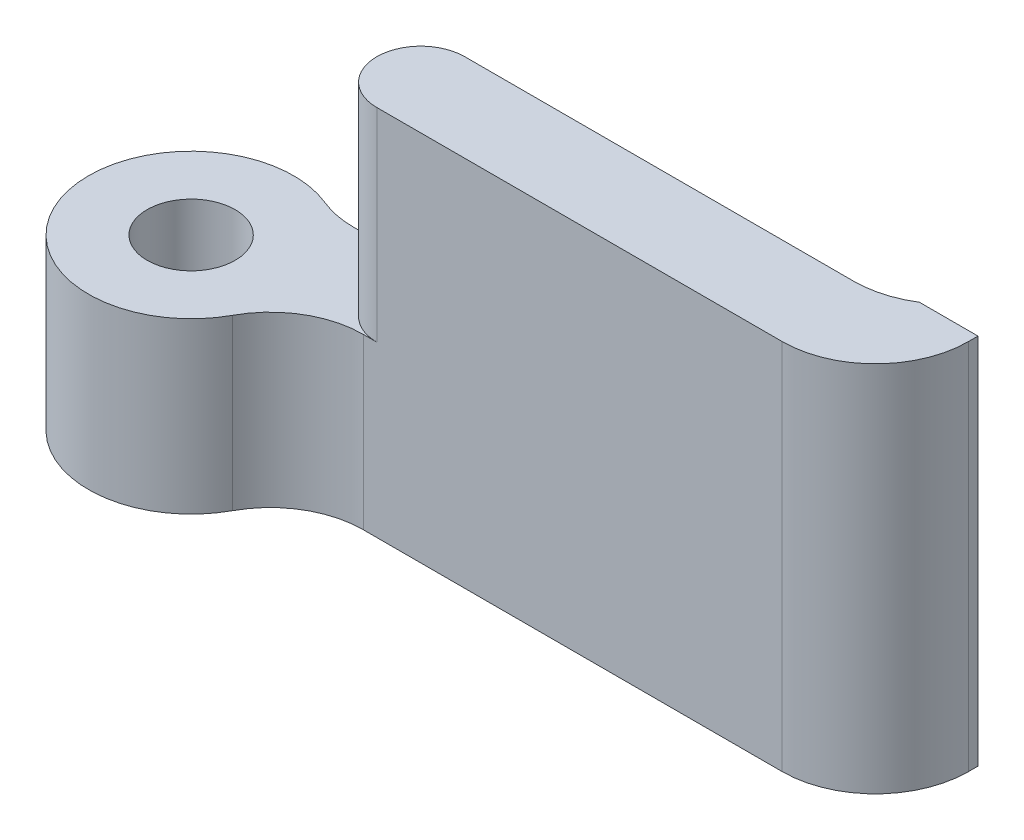
from build123d import *

# Parameters (mm, degrees)
SKETCH1_R           = 3.5
BOSS_EXTRUDE1_DEPTH = 12.7
CUT_EXTRUDE1_START  = -6.93
CUT_EXTRUDE1_DEPTH  = 6.93
SKETCH3_R           = 1.5
CUT_EXTRUDE2_DEPTH  = 6.77
SKETCH4_W           = 2
SKETCH4_H           = 0.5
BOSS_EXTRUDE2_DEPTH = 12.7
FILLET1_R           = 3.175
SKETCH5_R           = 2
CUT_EXTRUDE3_DEPTH  = 10
SKETCH6_R           = 1.585
CUT_EXTRUDE4_DEPTH  = 1.5


with BuildPart() as part:
    # Sketch1 → Boss-Extrude1 (new body)
    with BuildSketch(Plane(origin=(0, 0, 0), x_dir=(1, 0, 0), z_dir=(0, 1, 0))):
        with Locations((-22.063770306, 11.23554707)):
            Circle(SKETCH1_R)
        with BuildLine():
            ThreePointArc((-20.260994668, 14.23554707), (-19.017484475, 12.958957246), (-18.563770306, 11.23554707))
            Line((-18.563770306, 11.23554707), (1.266442488, 11.23554707))
            Line((1.266442488, 11.23554707), (1.266442488, 14.23554707))
            Line((1.266442488, 14.23554707), (-20.260994668, 14.23554707))
        make_face()
    extrude(amount=BOSS_EXTRUDE1_DEPTH)

    # Sketch2 → Cut-Extrude1 (cut)
    with BuildSketch(Plane(origin=(0, 12.7, 0), x_dir=(1, 0, 0), z_dir=(0, 1, 0)).offset(CUT_EXTRUDE1_START)):
        with BuildLine():
            Line((-18.563770306, 11.23554707), (-15.733557512, 11.23554707))
            ThreePointArc((-15.733557512, 11.23554707), (-17.233557512, 12.73554707), (-15.733557512, 14.23554707))
            Line((-15.733557512, 14.23554707), (-20.260994668, 14.23554707))
            ThreePointArc((-20.260994668, 14.23554707), (-25.110056137, 9.512136894), (-18.563770306, 11.23554707))
        make_face()
    extrude(amount=CUT_EXTRUDE1_DEPTH, mode=Mode.SUBTRACT)

    # Sketch3 → Cut-Extrude2 (cut, through all)
    with BuildSketch(Plane(origin=(0, 5.77, 0), x_dir=(1, 0, 0), z_dir=(0, 1, 0))):
        with Locations(Location((-22.063770306, 11.23554707, 0), (0, 0, 270))):  # turned: the seam where the file's is
            Circle(SKETCH3_R)
    extrude(amount=-CUT_EXTRUDE2_DEPTH, mode=Mode.SUBTRACT)

    # Sketch4 → Boss-Extrude2 (add)
    with BuildSketch(Plane(origin=(0, 12.7, 0), x_dir=(1, 0, 0), z_dir=(0, 1, 0))):
        with Locations((0.266442488, 14.48554707)):
            Rectangle(SKETCH4_W, SKETCH4_H)
        with BuildLine():
            Line((-2.472810226, 14.23554707), (-0.733557512, 14.23554707))
            Line((-0.733557512, 14.23554707), (-0.733557512, 14.73554707))
            ThreePointArc((-0.733557512, 14.73554707), (-1.567962172, 14.363028206), (-2.472810226, 14.23554707))
        make_face()
    extrude(amount=-BOSS_EXTRUDE2_DEPTH)

    # Fillet1
    fillet1_edges = [part.edges().sort_by_distance(p)[0] for p in [
        (-20.260994668, 2.885, -14.23554707),
        (-18.563770306, 2.885, -11.23554707),
        (1.266442488, 6.35, -11.23554707),
    ]]
    fillet(fillet1_edges, radius=FILLET1_R)

    # Sketch5 → Cut-Extrude3 (cut)
    with BuildSketch(Plane(origin=(0, 0, -14.23554707), x_dir=(-1, 0, 0), z_dir=(0, 0, -1))):
        with Locations((-37.221491695, -42.831378851)):
            Circle(SKETCH5_R)
        with Locations((-37.221491695, -47.531378851)):
            Circle(SKETCH5_R)
    extrude(amount=-CUT_EXTRUDE3_DEPTH, mode=Mode.SUBTRACT)

    # Sketch6 → Cut-Extrude4 (cut)
    with BuildSketch(Plane(origin=(0, 0, -14.23554707), x_dir=(-1, 0, 0), z_dir=(0, 0, -1))):
        with Locations((4.733557512, 6.35)):
            Circle(SKETCH6_R)
    extrude(amount=-CUT_EXTRUDE4_DEPTH, mode=Mode.SUBTRACT)


solid = part.part
